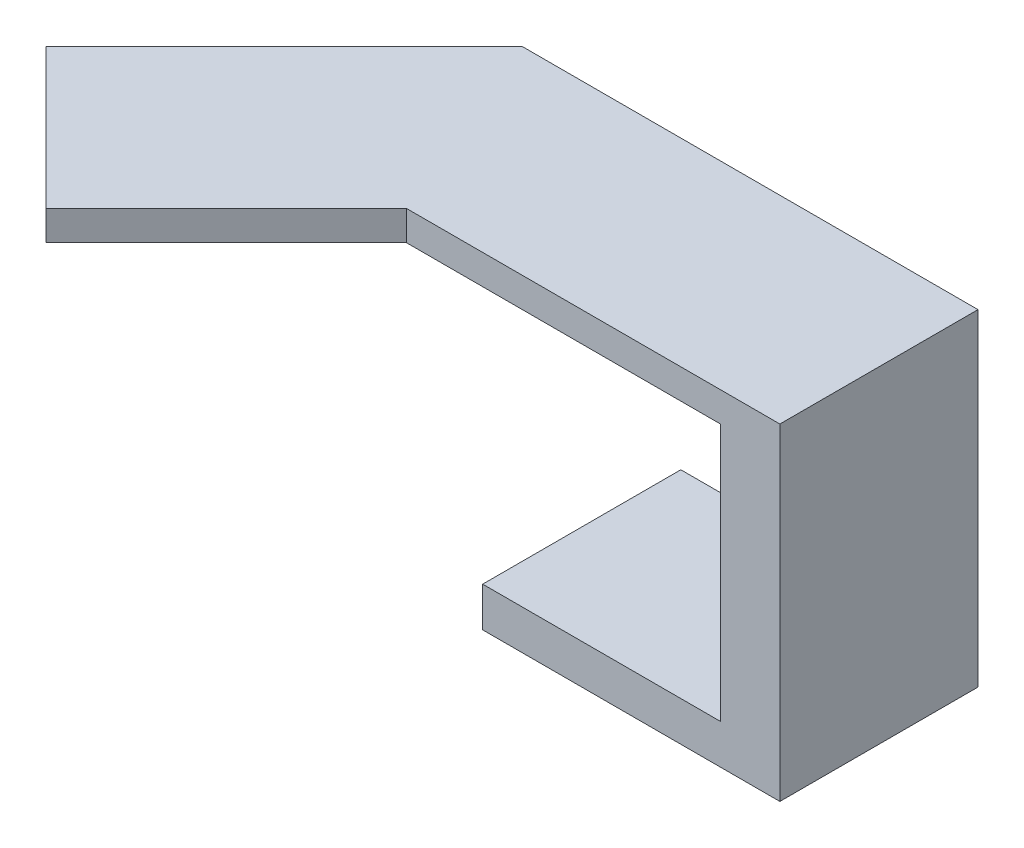
from build123d import *

# Parameters (mm, degrees)
BOSS_EXTRUDE1_DEPTH = 1.5
SKETCH2_W           = 3
SKETCH2_H           = 10
BOSS_EXTRUDE2_DEPTH = 15
SKETCH3_W           = 10
SKETCH3_H           = 2
BOSS_EXTRUDE3_DEPTH = 12


with BuildPart() as part:
    # Sketch1 → Boss-Extrude1 (new body)
    with BuildSketch(Plane(origin=(0, 0, 0), x_dir=(1, 0, 0), z_dir=(0, 1, 0))):
        Polygon((-10.25315493, 4.457893448), (-22.27397021, -7.562921833), (-15.202902398, -14.633989644), (-6.111019306, -5.542106552), (12.74684507, -5.542106552), (12.74684507, 4.457893448), align=None)
    extrude(amount=BOSS_EXTRUDE1_DEPTH)

    # Sketch2 → Boss-Extrude2 (add)
    with BuildSketch(Plane.XZ):
        with Locations((11.24684507, 0.542106552)):
            Rectangle(SKETCH2_W, SKETCH2_H)
    extrude(amount=BOSS_EXTRUDE2_DEPTH)

    # Sketch3 → Boss-Extrude3 (add)
    with BuildSketch(Plane.ZY.offset(-9.74684507)):
        with Locations((0.542106552, -14)):
            Rectangle(SKETCH3_W, SKETCH3_H)
    extrude(amount=BOSS_EXTRUDE3_DEPTH)


solid = part.part
